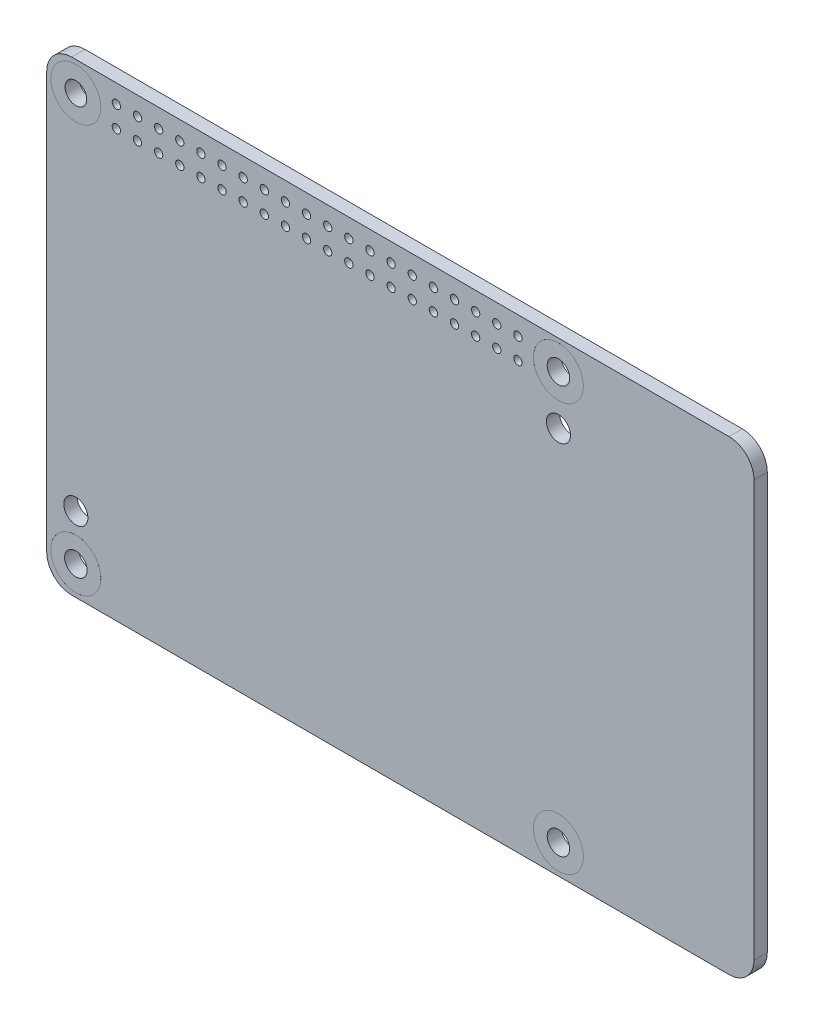
from build123d import *

# Parameters (mm, degrees)
BOSS_EXTRUDE1_DEPTH        = 1.6
SKETCH3_R                  = 3
CUT_EXTRUDE1_DEPTH         = 2.6
SKETCH4_R                  = 3
SKETCH4_R_2                = 1.35
BOSS_EXTRUDE2_DEPTH        = 1.7
BOSS_EXTRUDE2_2_DEPTH      = 1.7
BOSS_EXTRUDE2_3_DEPTH      = 1.7
SKETCH4_R_3                = 1.3
BOSS_EXTRUDE2_4_DEPTH      = 1.7
SKETCH6_R                  = 0.5
CUT_EXTRUDE3_DEPTH         = 2.7
SZKIC1_R                   = 1.45
WYTNIJ_WYCI_GNI_CIE1_DEPTH = 2.7


with BuildPart() as part:
    # Sketch1 → Boss-Extrude1 (new body)
    with BuildSketch(Plane.XY):
        with BuildLine():
            Line((-39.5, -28), (39.5, -28))
            ThreePointArc((39.5, -28), (41.621320344, -27.121320344), (42.5, -25))
            Line((42.5, -25), (42.5, 25))
            ThreePointArc((42.5, 25), (41.621320344, 27.121320344), (39.5, 28))
            Line((39.5, 28), (-39.5, 28))
            ThreePointArc((-39.5, 28), (-41.621320344, 27.121320344), (-42.5, 25))
            Line((-42.5, 25), (-42.5, -25))
            ThreePointArc((-42.5, -25), (-41.621320344, -27.121320344), (-39.5, -28))
        make_face()
    extrude(amount=BOSS_EXTRUDE1_DEPTH)

    # Sketch3 → Cut-Extrude1 (cut, through all)
    with BuildSketch(Plane.XY.offset(1.6)):
        with Locations((-39, 24.5)):
            Circle(SKETCH3_R)
        with Locations((-39, -24.5)):
            Circle(SKETCH3_R)
        with Locations((19, -24.5)):
            Circle(SKETCH3_R)
        with Locations((19, 24.5)):
            Circle(SKETCH3_R)
    extrude(amount=-CUT_EXTRUDE1_DEPTH, mode=Mode.SUBTRACT)

    # Sketch6 → Cut-Extrude3 (cut, through all)
    with BuildSketch(Plane.XY.offset(1.6)):
        with Locations((-34.13, 25.77)):
            Circle(SKETCH6_R)
        with Locations((-34.13, 23.23)):
            Circle(SKETCH6_R)
        with Locations((-31.59, 25.77)):
            Circle(SKETCH6_R)
        with Locations((-31.59, 23.23)):
            Circle(SKETCH6_R)
        with Locations((-29.05, 25.77)):
            Circle(SKETCH6_R)
        with Locations((-29.05, 23.23)):
            Circle(SKETCH6_R)
        with Locations((-26.51, 25.77)):
            Circle(SKETCH6_R)
        with Locations((-26.51, 23.23)):
            Circle(SKETCH6_R)
        with Locations((-23.97, 25.77)):
            Circle(SKETCH6_R)
        with Locations((-23.97, 23.23)):
            Circle(SKETCH6_R)
        with Locations((-21.43, 25.77)):
            Circle(SKETCH6_R)
        with Locations((-21.43, 23.23)):
            Circle(SKETCH6_R)
        with Locations((-18.89, 25.77)):
            Circle(SKETCH6_R)
        with Locations((-18.89, 23.23)):
            Circle(SKETCH6_R)
        with Locations((-16.35, 25.77)):
            Circle(SKETCH6_R)
        with Locations((-16.35, 23.23)):
            Circle(SKETCH6_R)
        with Locations((-13.81, 25.77)):
            Circle(SKETCH6_R)
        with Locations((-13.81, 23.23)):
            Circle(SKETCH6_R)
        with Locations((-11.27, 25.77)):
            Circle(SKETCH6_R)
        with Locations((-11.27, 23.23)):
            Circle(SKETCH6_R)
        with Locations((-8.73, 25.77)):
            Circle(SKETCH6_R)
        with Locations((-8.73, 23.23)):
            Circle(SKETCH6_R)
        with Locations((-6.19, 25.77)):
            Circle(SKETCH6_R)
        with Locations((-6.19, 23.23)):
            Circle(SKETCH6_R)
        with Locations((-3.65, 25.77)):
            Circle(SKETCH6_R)
        with Locations((-3.65, 23.23)):
            Circle(SKETCH6_R)
        with Locations((-1.11, 25.77)):
            Circle(SKETCH6_R)
        with Locations((-1.11, 23.23)):
            Circle(SKETCH6_R)
        with Locations((1.43, 25.77)):
            Circle(SKETCH6_R)
        with Locations((1.43, 23.23)):
            Circle(SKETCH6_R)
        with Locations((3.97, 25.77)):
            Circle(SKETCH6_R)
        with Locations((3.97, 23.23)):
            Circle(SKETCH6_R)
        with Locations((6.51, 25.77)):
            Circle(SKETCH6_R)
        with Locations((6.51, 23.23)):
            Circle(SKETCH6_R)
        with Locations((9.05, 25.77)):
            Circle(SKETCH6_R)
        with Locations((9.05, 23.23)):
            Circle(SKETCH6_R)
        with Locations((11.59, 25.77)):
            Circle(SKETCH6_R)
        with Locations((11.59, 23.23)):
            Circle(SKETCH6_R)
        with Locations((14.13, 25.77)):
            Circle(SKETCH6_R)
        with Locations((14.13, 23.23)):
            Circle(SKETCH6_R)
    extrude(amount=-CUT_EXTRUDE3_DEPTH, mode=Mode.SUBTRACT)

    # Szkic1 → Wytnij-wyciągnięcie1 (cut, through all)
    with BuildSketch(Plane.XY.offset(1.6)):
        with Locations((19, 18.6)):
            Circle(SZKIC1_R)
        with Locations((-39, -19)):
            Circle(SZKIC1_R)
    extrude(amount=-WYTNIJ_WYCI_GNI_CIE1_DEPTH, mode=Mode.SUBTRACT)


with BuildPart() as body_2:
    # Sketch4 → Boss-Extrude2 (new body)
    with BuildSketch(Plane.XY.offset(1.6)):
        with Locations((-39, -24.5)):
            Circle(SKETCH4_R)
        with Locations((-39, -24.5)):
            Circle(SKETCH4_R_2, mode=Mode.SUBTRACT)
    extrude(amount=-BOSS_EXTRUDE2_DEPTH)


with BuildPart() as body_3:
    # Sketch4 → Boss-Extrude2 2 (new body)
    with BuildSketch(Plane.XY.offset(1.6)):
        with Locations((19, -24.5)):
            Circle(SKETCH4_R)
        with Locations((19, -24.5)):
            Circle(SKETCH4_R_2, mode=Mode.SUBTRACT)
    extrude(amount=-BOSS_EXTRUDE2_2_DEPTH)


with BuildPart() as body_4:
    # Sketch4 → Boss-Extrude2 3 (new body)
    with BuildSketch(Plane.XY.offset(1.6)):
        with Locations((19, 24.5)):
            Circle(SKETCH4_R)
        with Locations((19, 24.5)):
            Circle(SKETCH4_R_2, mode=Mode.SUBTRACT)
    extrude(amount=-BOSS_EXTRUDE2_3_DEPTH)


with BuildPart() as body_5:
    # Sketch4 → Boss-Extrude2 4 (new body)
    with BuildSketch(Plane.XY.offset(1.6)):
        with Locations((-39, 24.5)):
            Circle(SKETCH4_R)
        with Locations((-39, 24.5)):
            Circle(SKETCH4_R_3, mode=Mode.SUBTRACT)
    extrude(amount=-BOSS_EXTRUDE2_4_DEPTH)


solid = Compound([part.part, body_2.part, body_3.part, body_4.part, body_5.part])
